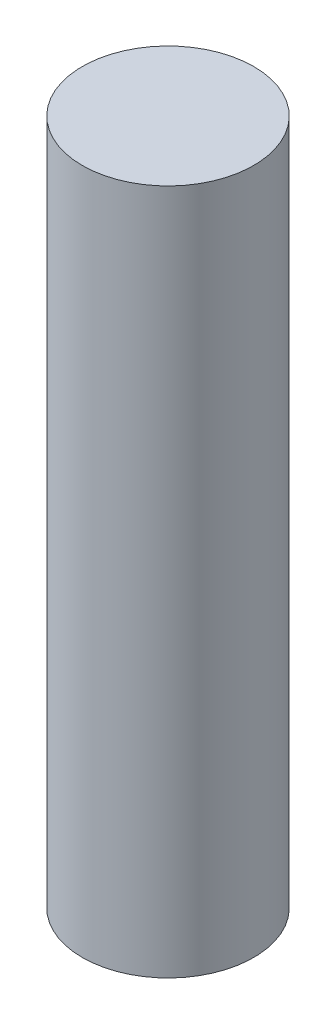
from build123d import *

# Parameters (mm, degrees)
SKETCH1_W = 1.5
SKETCH1_H = 12


with BuildPart() as part:
    # Sketch1 → Revolve1 (revolve)
    with BuildSketch(Plane.XY):
        with Locations((-0.75, 6)):
            Rectangle(SKETCH1_W, SKETCH1_H)
    revolve(axis=Axis((0, 0, 0), (0, 1, 0)))


solid = part.part
